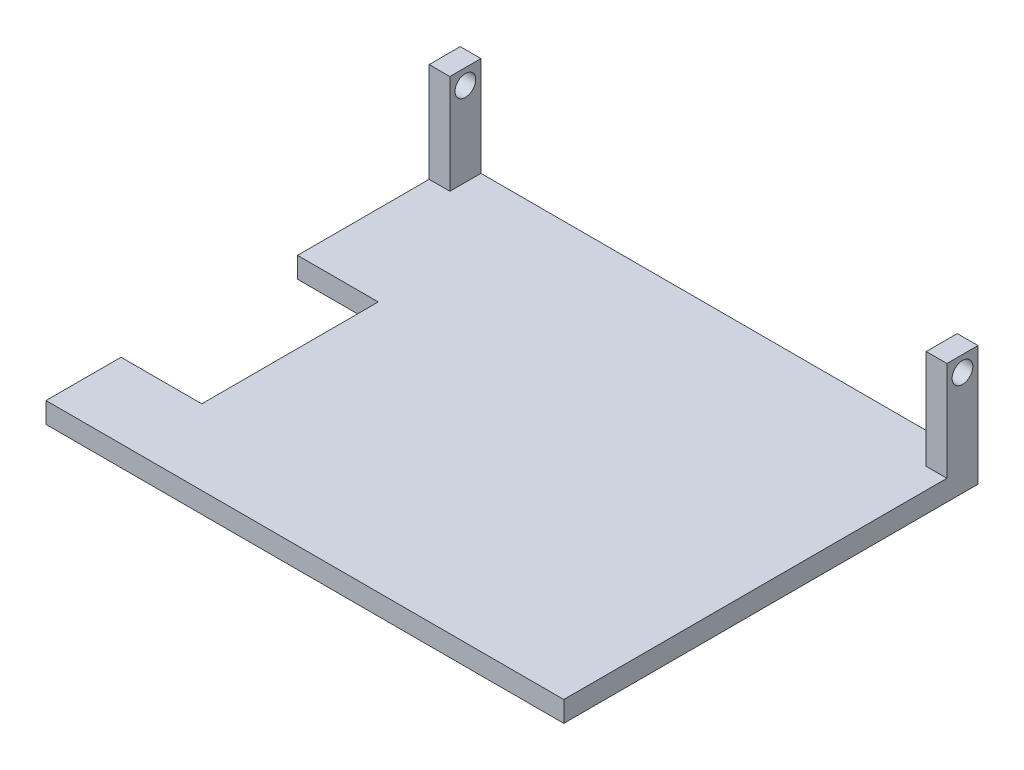
from build123d import *

# Parameters (mm, degrees)
BOSS_EXTRU_1_DEPTH      = 10
ESQUISSE2_W             = 15
ESQUISSE2_H             = 48
BOSS_EXTRU_2_DEPTH      = 250
ESQUISSE5_W             = 230
ESQUISSE5_H             = 48
ENL_V_MAT_EXTRU_1_DEPTH = 15
ESQUISSE6_R             = 5
ENL_V_MAT_EXTRU_2_DEPTH = 250


with BuildPart() as part:
    # Esquisse1 → Boss.-Extru.1 (new body)
    with BuildSketch(Plane(origin=(0, 0, 0), x_dir=(1, 0, 0), z_dir=(0, 1, 0))):
        Polygon((-210, 0), (-250, 0), (-250, 36.228880697), (-211.024769455, 36.228880697), (-211.024769455, 121.442108629), (-250, 121.442108629), (-250, 200), (-211.024769455, 200), (0, 200), (0, 0), align=None)
    extrude(amount=BOSS_EXTRU_1_DEPTH)

    # Esquisse2 → Boss.-Extru.2 (add)
    with BuildSketch(Plane(origin=(0, 0, 0), x_dir=(0, 0, -1), z_dir=(1, 0, 0))):
        with Locations((192.5, 34)):
            Rectangle(ESQUISSE2_W, ESQUISSE2_H)
    extrude(amount=-BOSS_EXTRU_2_DEPTH)

    # Esquisse5 → Enlèv. mat.-Extru.1 (cut)
    with BuildSketch(Plane.XY.offset(-185)):
        with Locations((-125, 34)):
            Rectangle(ESQUISSE5_W, ESQUISSE5_H)
    extrude(amount=-ENL_V_MAT_EXTRU_1_DEPTH, mode=Mode.SUBTRACT)

    # Esquisse6 → Enlèv. mat.-Extru.2 (cut)
    with BuildSketch(Plane(origin=(0, 0, 0), x_dir=(0, 0, -1), z_dir=(1, 0, 0))):
        with Locations((192.5, 50.5)):
            Circle(ESQUISSE6_R)
    extrude(amount=-ENL_V_MAT_EXTRU_2_DEPTH, mode=Mode.SUBTRACT)


solid = part.part
